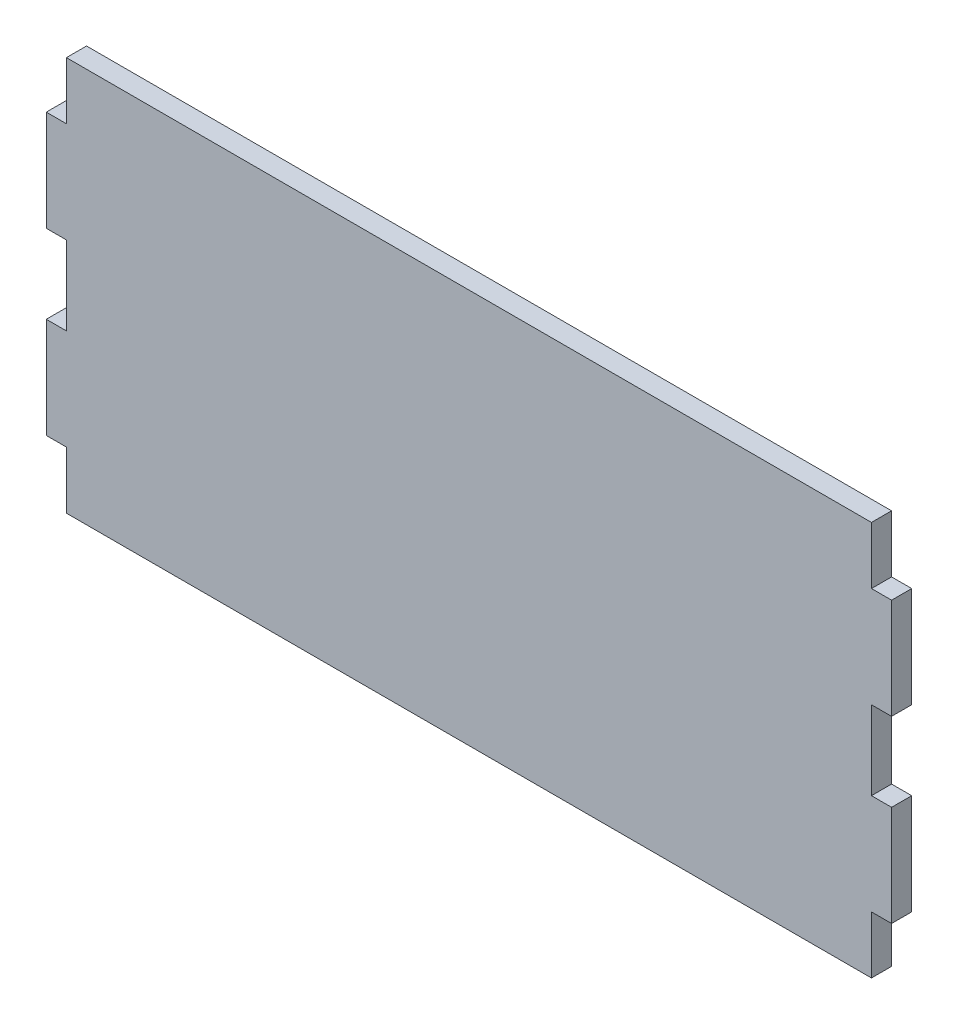
from build123d import *

# Parameters (mm, degrees)
BOSS_EXTRUDE1_DEPTH = 15


with BuildPart() as part:
    # Sketch1 → Boss-Extrude1 (new body)
    with BuildSketch(Plane.XY):
        Polygon((0, 0), (600, 0), (600, 42.675), (615, 42.675), (615, 117.675), (600, 117.675), (600, 176.375), (615, 176.375), (615, 251.375), (600, 251.375), (600, 294.05), (0, 294.05), (0, 251.375), (-15, 251.375), (-15, 176.375), (0, 176.375), (0, 117.675), (-15, 117.675), (-15, 42.675), (0, 42.675), align=None)
    extrude(amount=BOSS_EXTRUDE1_DEPTH)


solid = part.part
